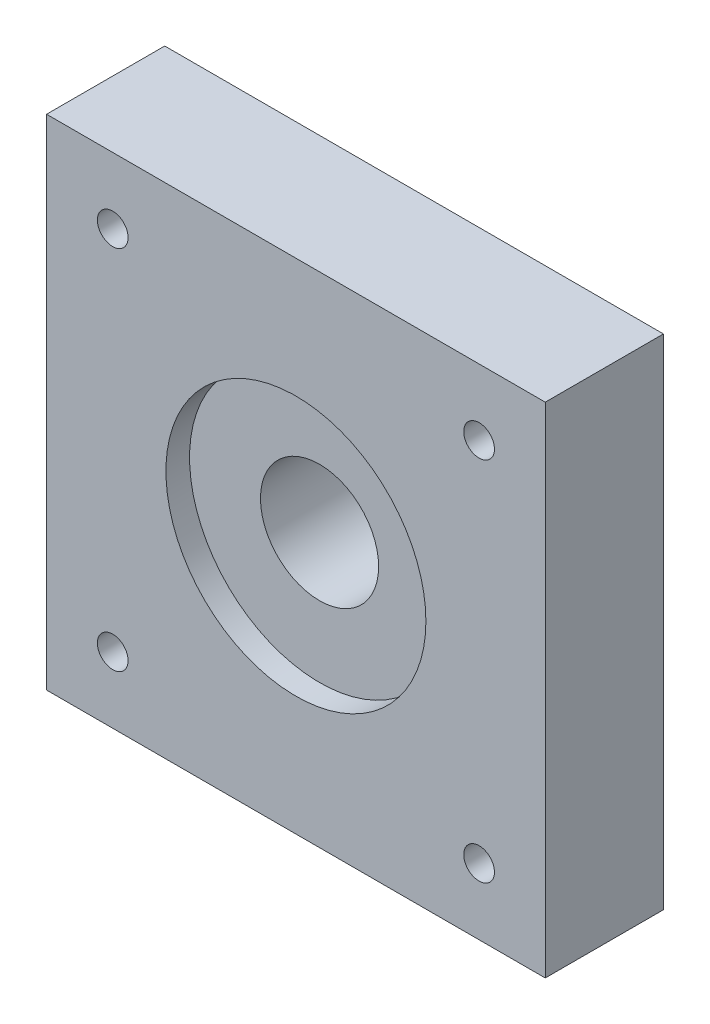
from build123d import *

# Parameters (mm, degrees)
SKETCH_1_W          = 42.2
SKETCH_1_H          = 42.2
EXTRUDE_1_DEPTH     = 10
SKETCH_2_R          = 1.6
SKETCH_2_R_2        = 3
CUT_EXTRUDE_1_DEPTH = 6
SKETCH_3_R          = 11
CUT_EXTRUDE_2_DEPTH = 2
SKETCH_4_R          = 5
CUT_EXTRUDE_3_DEPTH = 11
SKETCH_5_R          = 1.3
CUT_EXTRUDE_4_DEPTH = 11


with BuildPart() as part:
    # 草图1 → 凸台-拉伸1 (new body)
    with BuildSketch(Plane.XY):
        Rectangle(SKETCH_1_W, SKETCH_1_H)
    extrude(amount=EXTRUDE_1_DEPTH)

    # 草图2 → 切除-拉伸1 (cut)
    with BuildSketch(Plane(origin=(0, 0, 0), x_dir=(-1, 0, 0), z_dir=(0, 0, -1))):
        with Locations((12.5, 0)):
            Circle(SKETCH_2_R)
        with Locations((0, -12.5)):
            Circle(SKETCH_2_R)
        with Locations((-12.5, 0)):
            Circle(SKETCH_2_R)
        with Locations((0, 12.5)):
            Circle(SKETCH_2_R)
        with Locations((-15.5, 15.5)):
            Circle(SKETCH_2_R_2)
        with Locations((15.5, 15.5)):
            Circle(SKETCH_2_R_2)
        with Locations((15.5, -15.5)):
            Circle(SKETCH_2_R_2)
        with Locations((-15.5, -15.5)):
            Circle(SKETCH_2_R_2)
    extrude(amount=-CUT_EXTRUDE_1_DEPTH, mode=Mode.SUBTRACT)

    # 草图3 → 切除-拉伸2 (cut)
    with BuildSketch(Plane.XY.offset(10)):
        Circle(SKETCH_3_R)
    extrude(amount=-CUT_EXTRUDE_2_DEPTH, mode=Mode.SUBTRACT)

    # 草图4 → 切除-拉伸3 (cut, through all)
    with BuildSketch(Plane(origin=(0, 0, 0), x_dir=(-1, 0, 0), z_dir=(0, 0, -1))):
        Circle(SKETCH_4_R)
    extrude(amount=-CUT_EXTRUDE_3_DEPTH, mode=Mode.SUBTRACT)

    # 草图5 → 切除-拉伸4 (cut, through all)
    with BuildSketch(Plane.XY.offset(10)):
        with Locations((15.5, -15.5)):
            Circle(SKETCH_5_R)
        with Locations((-15.5, -15.5)):
            Circle(SKETCH_5_R)
        with Locations((-15.5, 15.5)):
            Circle(SKETCH_5_R)
        with Locations((15.5, 15.5)):
            Circle(SKETCH_5_R)
    extrude(amount=-CUT_EXTRUDE_4_DEPTH, mode=Mode.SUBTRACT)


solid = part.part
